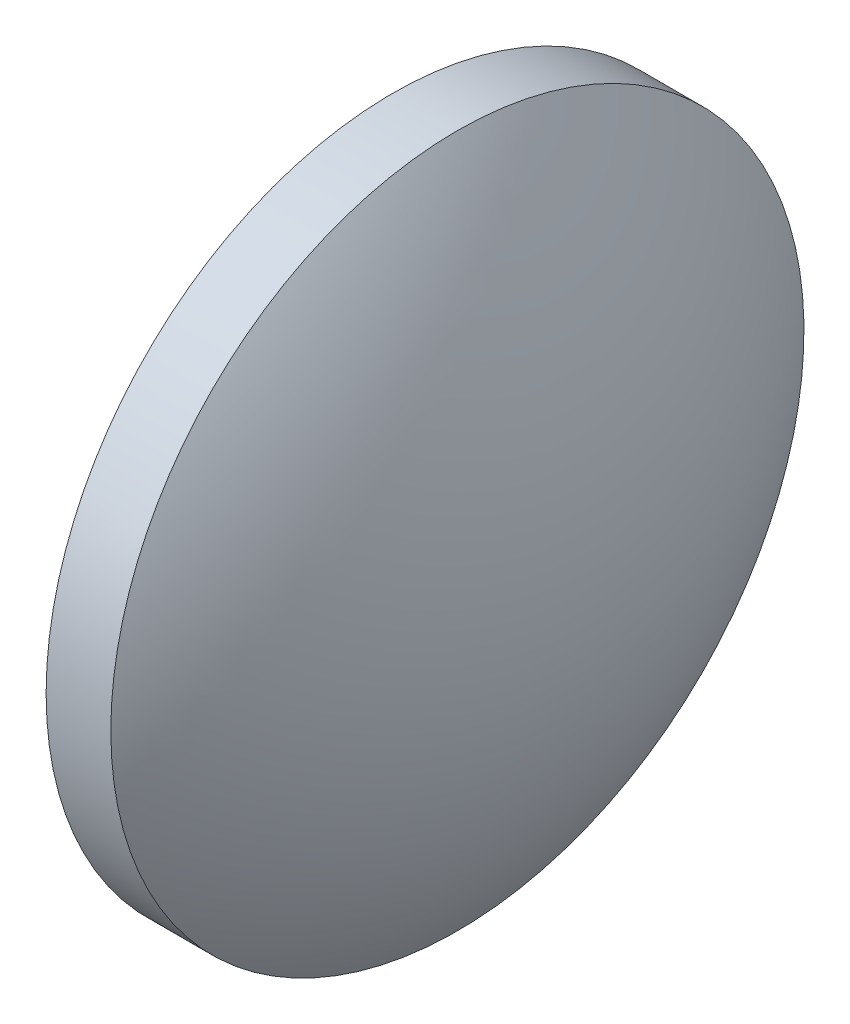
from build123d import *


with BuildPart() as part:
    # 草图1 → 旋转1 (revolve)
    with BuildSketch(Plane.XY):
        with BuildLine():
            Line((345.8591158, 134.701231316), (345.8591158, 140.701231316))
            Line((345.8591158, 140.701231316), (346.9791158, 140.701231316))
            ThreePointArc((346.9791158, 140.701231316), (348.378113672, 137.84505065), (348.8591158, 134.701231316))
            Line((348.8591158, 134.701231316), (345.8591158, 134.701231316))
        make_face()
    revolve(axis=Axis((327.38568814, 134.701231316, 0), (1, 0, 0)))


solid = part.part
